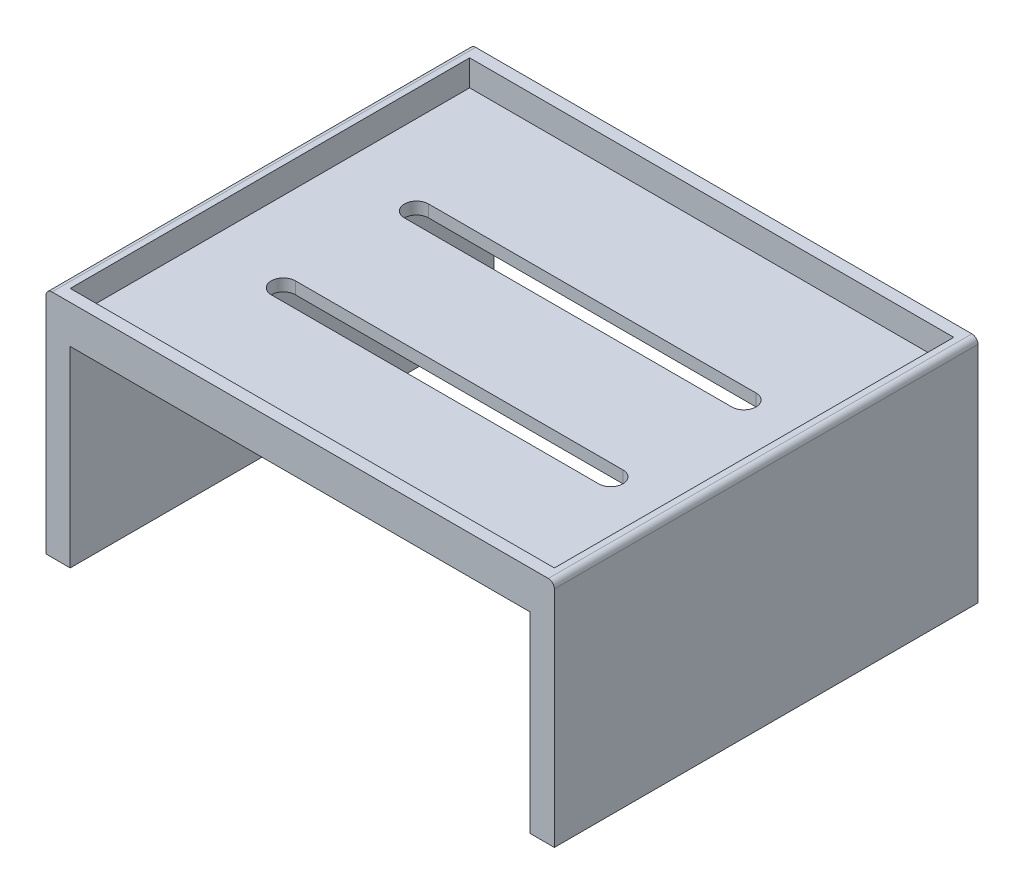
from build123d import *

# Parameters (mm, degrees)
BOSS_EXTRUDE1_DEPTH  = 350
SKETCH4_W            = 400
SKETCH4_H            = 330
CUT_EXTRUDE1_DEPTH   = 21.5
SKETCH5_W            = 130
SKETCH5_H            = 130
CUT_EXTRUDE2_DEPTH   = 30
FILLET1_R            = 5
SKETCH15_W           = 130
SKETCH15_H           = 10
CUT_EXTRUDE3_DEPTH   = 25
SKETCH16_W           = 130
SKETCH16_H           = 10
BOSS_EXTRUDE6_DEPTH  = 25
SKETCH22_W           = 130
SKETCH22_H           = 130
BOSS_EXTRUDE11_DEPTH = 10
BOSS_EXTRUDE12_DEPTH = 10
CUT_EXTRUDE4_DEPTH   = 10


with BuildPart() as part:
    # Sketch3 → Boss-Extrude1 (new body)
    with BuildSketch(Plane.XY):
        Polygon((-76.099744246, 110.652173913), (343.900255754, 110.652173913), (343.900255754, -79.347826087), (323.900255754, -79.347826087), (323.900255754, 79.152173913), (-56.099744246, 79.152173913), (-56.099744246, -79.347826087), (-76.099744246, -79.347826087), align=None)
    extrude(amount=-BOSS_EXTRUDE1_DEPTH)

    # Sketch4 → Cut-Extrude1 (cut)
    with BuildSketch(Plane(origin=(0, 110.652173913, 0), x_dir=(1, 0, 0), z_dir=(0, 1, 0))):
        with Locations((133.900255754, 175)):
            Rectangle(SKETCH4_W, SKETCH4_H)
    extrude(amount=-CUT_EXTRUDE1_DEPTH, mode=Mode.SUBTRACT)

    # Sketch5 → Cut-Extrude2 (cut)
    with BuildSketch(Plane(origin=(0, 89.152173913, 0), x_dir=(1, 0, 0), z_dir=(0, 1, 0))):
        with Locations((33.900255754, 110)):
            Rectangle(SKETCH5_W, SKETCH5_H)
        with BuildLine():
            Line((-21.099744246, 247.552781264), (88.900255754, 247.552781264))
            ThreePointArc((88.900255754, 247.552781264), (98.900255754, 237.552781264), (88.900255754, 227.552781264))
            Line((88.900255754, 227.552781264), (-21.099744246, 227.552781264))
            ThreePointArc((-21.099744246, 227.552781264), (-31.099744246, 237.552781264), (-21.099744246, 247.552781264))
        make_face()
        with BuildLine():
            Line((-21.099744246, 315.266550997), (88.900255754, 315.266550997))
            ThreePointArc((88.900255754, 315.266550997), (98.900255754, 305.266550997), (88.900255754, 295.266550997))
            Line((88.900255754, 295.266550997), (-21.099744246, 295.266550997))
            ThreePointArc((-21.099744246, 295.266550997), (-31.099744246, 305.266550997), (-21.099744246, 315.266550997))
        make_face()
    extrude(amount=-CUT_EXTRUDE2_DEPTH, mode=Mode.SUBTRACT)

    # Fillet1
    fillet1_edges = [part.edges().sort_by_distance(p)[0] for p in [
        (-76.099744246, 110.652173913, -175),
        (343.900255754, 110.652173913, -175),
    ]]
    fillet(fillet1_edges, radius=FILLET1_R)

    # Sketch15 → Cut-Extrude3 (cut)
    with BuildSketch(Plane.XY.offset(-175)):
        with Locations((33.900255754, 84.152173913)):
            Rectangle(SKETCH15_W, SKETCH15_H)
    extrude(amount=-CUT_EXTRUDE3_DEPTH, mode=Mode.SUBTRACT)

    # Sketch16 → Boss-Extrude6 (add)
    with BuildSketch(Plane(origin=(0, 0, -45), x_dir=(-1, 0, 0), z_dir=(0, 0, -1))):
        with Locations((-33.900255754, 84.152173913)):
            Rectangle(SKETCH16_W, SKETCH16_H)
    extrude(amount=BOSS_EXTRUDE6_DEPTH)

    # Sketch22 → Boss-Extrude11 (add)
    with BuildSketch(Plane(origin=(0, 89.152173913, 0), x_dir=(1, 0, 0), z_dir=(0, 1, 0))):
        with Locations((33.900255754, 135)):
            Rectangle(SKETCH22_W, SKETCH22_H)
    extrude(amount=-BOSS_EXTRUDE11_DEPTH)

    # Sketch23 → Boss-Extrude12 (add)
    with BuildSketch(Plane(origin=(0, 89.152173913, 0), x_dir=(1, 0, 0), z_dir=(0, 1, 0))):
        with BuildLine():
            ThreePointArc((-21.099744246, 295.266550997), (-31.099744246, 305.266550997), (-21.099744246, 315.266550997))
            Line((-21.099744246, 315.266550997), (88.900255754, 315.266550997))
            ThreePointArc((88.900255754, 315.266550997), (98.900255754, 305.266550997), (88.900255754, 295.266550997))
            Line((88.900255754, 295.266550997), (-21.099744246, 295.266550997))
        make_face()
        with BuildLine():
            ThreePointArc((-21.099744246, 227.552781264), (-31.099744246, 237.552781264), (-21.099744246, 247.552781264))
            Line((-21.099744246, 247.552781264), (88.900255754, 247.552781264))
            ThreePointArc((88.900255754, 247.552781264), (98.900255754, 237.552781264), (88.900255754, 227.552781264))
            Line((88.900255754, 227.552781264), (-21.099744246, 227.552781264))
        make_face()
    extrude(amount=-BOSS_EXTRUDE12_DEPTH)

    # Sketch24 → Cut-Extrude4 (cut)
    with BuildSketch(Plane(origin=(0, 89.152173913, 0), x_dir=(1, 0, 0), z_dir=(0, 1, 0))):
        with BuildLine():
            Line((0, 240), (270.518831375, 240))
            ThreePointArc((270.518831375, 240), (280.518831375, 230), (270.518831375, 220))
            Line((270.518831375, 220), (0, 220))
            ThreePointArc((0, 220), (-10, 230), (0, 240))
        make_face()
        with BuildLine():
            Line((270.518831375, 110), (0, 110))
            ThreePointArc((0, 110), (-10, 120), (0, 130))
            Line((0, 130), (270.518831375, 130))
            ThreePointArc((270.518831375, 130), (280.518831375, 120), (270.518831375, 110))
        make_face()
    extrude(amount=-CUT_EXTRUDE4_DEPTH, mode=Mode.SUBTRACT)


solid = part.part
